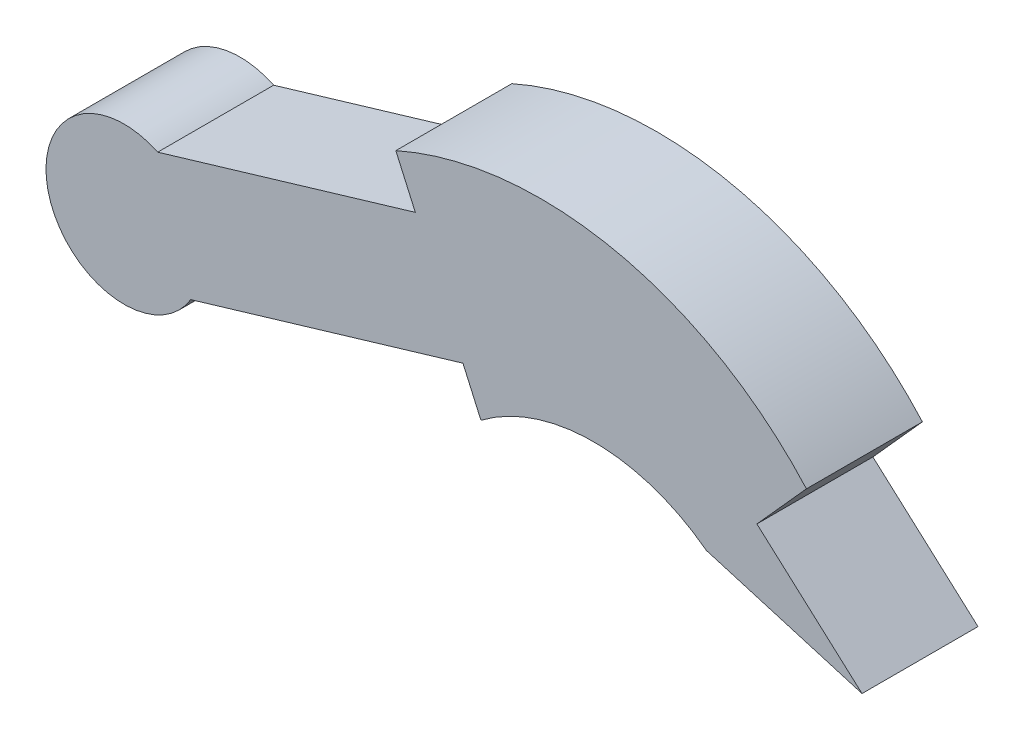
from build123d import *

# Parameters (mm, degrees)
BOSS_EXTRUDE1_DEPTH = 1.524


with BuildPart() as part:
    # Sketch1 → Boss-Extrude1 (new body)
    with BuildSketch(Plane.XY):
        with BuildLine():
            Line((25.018211481, 1.458274504), (28.403024501, 2.465831103))
            Line((28.403024501, 2.465831103), (28.147078807, 3.040199114))
            ThreePointArc((28.147078807, 3.040199114), (31.031837949, 3.343352077), (33.541663921, 1.889216381))
            Line((33.541663921, 1.889216381), (32.890976581, 1.164259908))
            Line((32.890976581, 1.164259908), (34.272042889, -0.07532122))
            Line((34.272042889, -0.07532122), (32.226452866, 0.530981017))
            ThreePointArc((32.226452866, 0.530981017), (30.745835594, 1.027103578), (29.265218322, 0.530981017))
            Line((29.265218322, 0.530981017), (29.028606423, 1.061962035))
            Line((29.028606423, 1.061962035), (25.453006053, -0.002386196))
            ThreePointArc((25.453006053, -0.002386196), (23.593059825, 0.239006946), (25.018211481, 1.458274504))
        make_face()
    extrude(amount=-BOSS_EXTRUDE1_DEPTH)


solid = part.part
